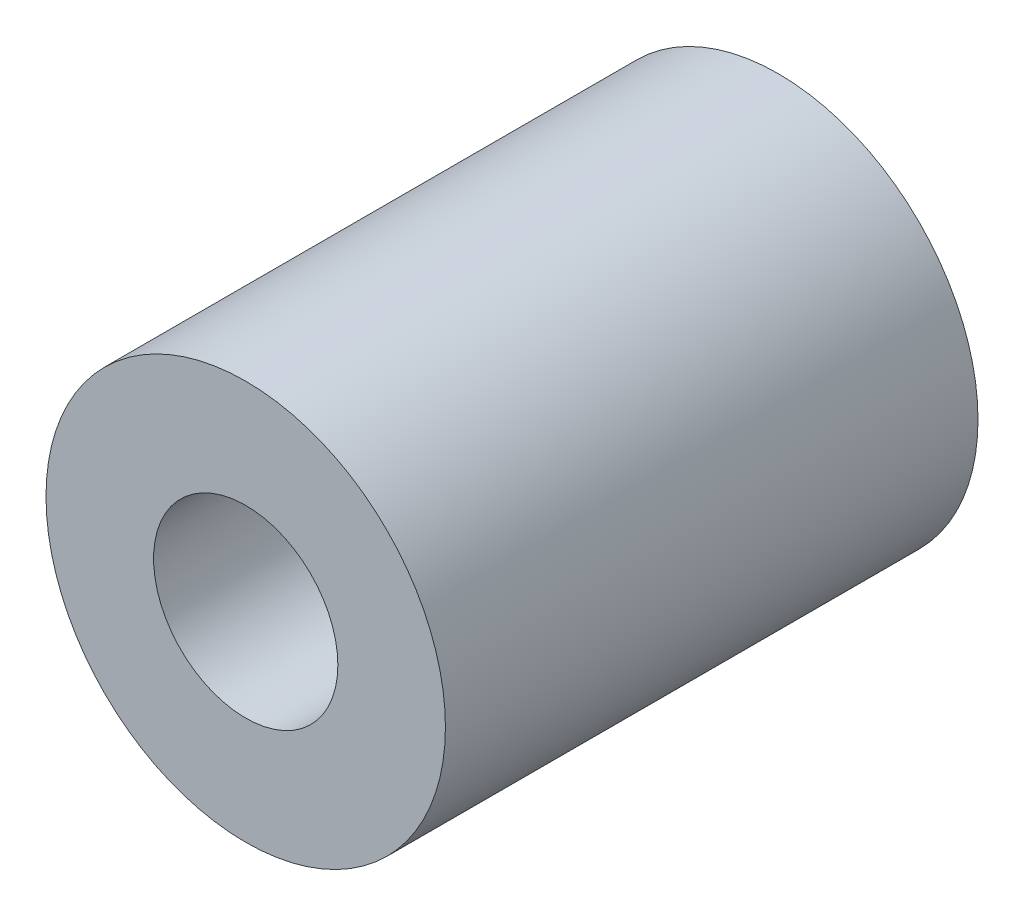
from build123d import *

# Parameters (mm, degrees)
SKETCH1_R           = 4.7625
SKETCH1_R_2         = 2.1971
BOSS_EXTRUDE1_DEPTH = 6.35
SKETCH2_R           = 1.25
CUT_EXTRUDE1_DEPTH  = 5.7625


with BuildPart() as part:
    # Sketch1 → Boss-Extrude1 (new body, symmetric)
    with BuildSketch(Plane.XY):
        Circle(SKETCH1_R)
        Circle(SKETCH1_R_2, mode=Mode.SUBTRACT)
    extrude(amount=BOSS_EXTRUDE1_DEPTH, both=True)

    # Sketch2 → Cut-Extrude1 (cut, through all)
    with BuildSketch(Plane(origin=(0, 0, 0), x_dir=(1, 0, 0), z_dir=(0, 1, 0))):
        Circle(SKETCH2_R)
    extrude(amount=-CUT_EXTRUDE1_DEPTH, mode=Mode.SUBTRACT)


solid = part.part
